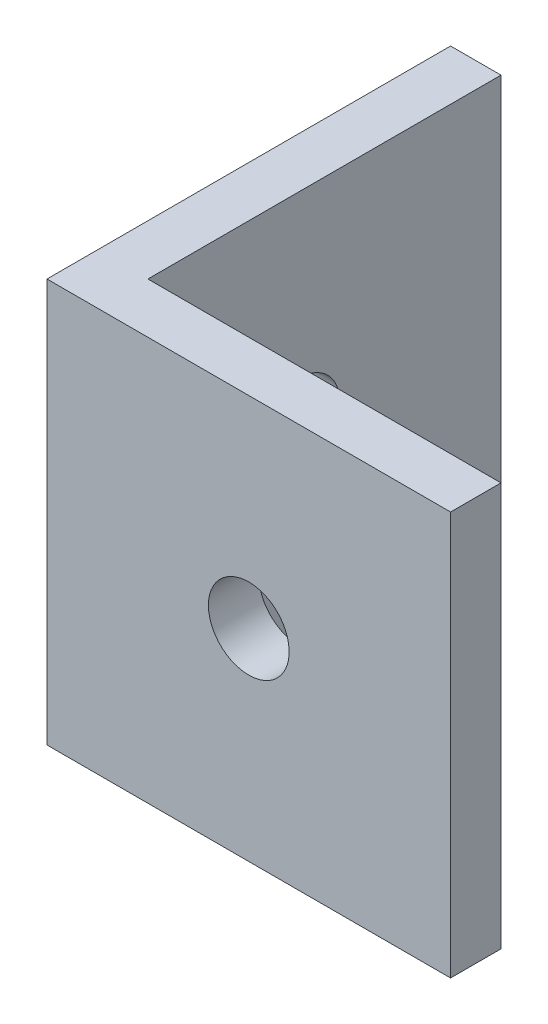
from build123d import *

# Parameters (mm, degrees)
BOSS_EXTRUDE1_DEPTH = 25.4
SKETCH2_R           = 2.54
CUT_EXTRUDE1_DEPTH  = 25.4
SKETCH3_R           = 2.54
CUT_EXTRUDE2_DEPTH  = 25.4


with BuildPart() as part:
    # Sketch1 → Boss-Extrude1 (new body)
    with BuildSketch(Plane(origin=(0, 0, 0), x_dir=(1, 0, 0), z_dir=(0, 1, 0))):
        Polygon((0, 0), (3.175, 0), (25.4, 0), (25.4, 3.175), (3.175, 3.175), (3.175, 25.4), (0, 25.4), align=None)
    extrude(amount=BOSS_EXTRUDE1_DEPTH)

    # Sketch2 → Cut-Extrude1 (cut)
    with BuildSketch(Plane(origin=(3.175, 0, 0), x_dir=(0, 0, -1), z_dir=(1, 0, 0))):
        with Locations((12.7, 12.7)):
            Circle(SKETCH2_R)
    extrude(amount=-CUT_EXTRUDE1_DEPTH, mode=Mode.SUBTRACT)

    # Sketch3 → Cut-Extrude2 (cut)
    with BuildSketch(Plane(origin=(0, 0, -3.175), x_dir=(-1, 0, 0), z_dir=(0, 0, -1))):
        with Locations((-12.7, 12.7)):
            Circle(SKETCH3_R)
    extrude(amount=-CUT_EXTRUDE2_DEPTH, mode=Mode.SUBTRACT)


solid = part.part
